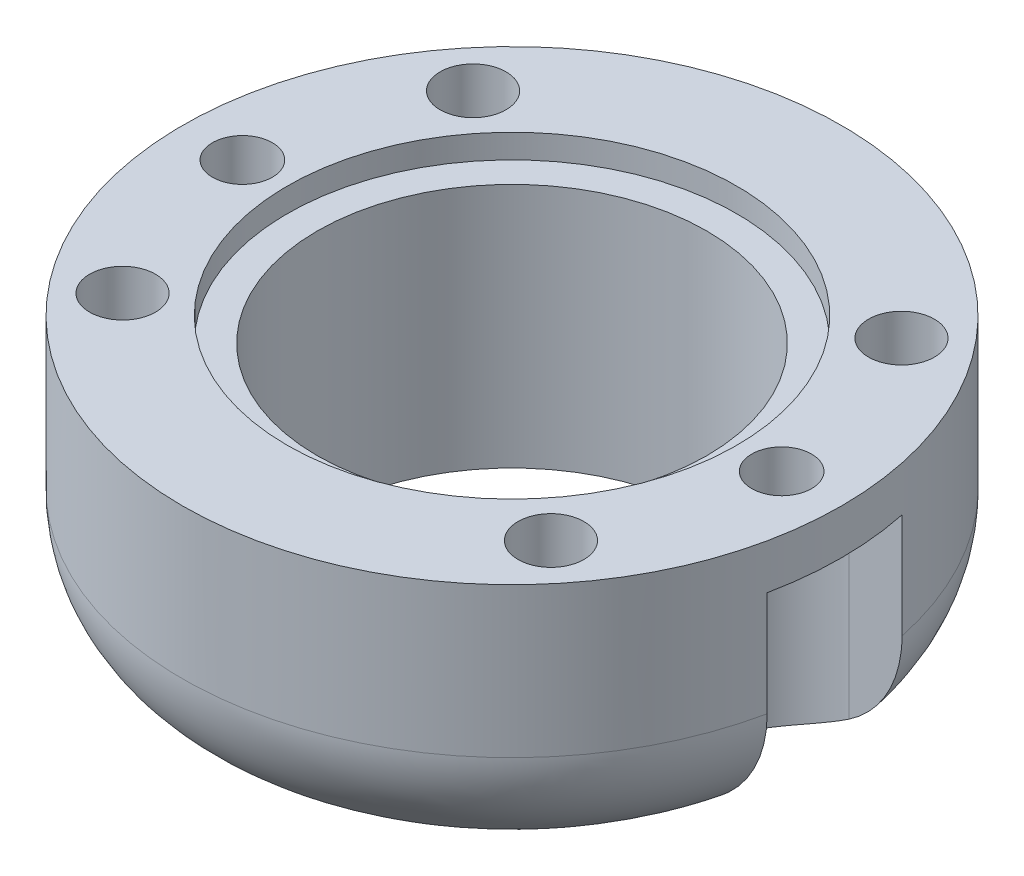
from build123d import *

# Parameters (mm, degrees)
SKETCH1_R           = 6.5
BOSS_EXTRUDE1_DEPTH = 9
SKETCH2_R           = 1.1
CUT_EXTRUDE1_DEPTH  = 3
SKETCH3_R           = 1
CUT_EXTRUDE2_DEPTH  = 20
CUT_EXTRUDE3_DEPTH  = 7.5
SKETCH6_W           = 6.8
SKETCH6_H           = 6.8
CUT_EXTRUDE4_DEPTH  = 5
SKETCH7_W           = 2.4
SKETCH7_H           = 2.4
CUT_EXTRUDE5_DEPTH  = 5
FILLET2_R           = 4
SKETCH8_R           = 1
CUT_EXTRUDE6_DEPTH  = 20
SKETCH9_R           = 7.5
CUT_EXTRUDE7_DEPTH  = 0.8
SKETCH11_W          = 5
SKETCH11_H          = 1
BOSS_EXTRUDE2_DEPTH = 5
SKETCH12_W          = 53.006357488
SKETCH12_H          = 54.029399369
SKETCH12_R          = 11
CUT_EXTRUDE9_DEPTH  = 10
FILLET3_R           = 4


with BuildPart() as part:
    # Sketch1 → Boss-Extrude1 (new body)
    with BuildSketch(Plane(origin=(0, 0, 0), x_dir=(1, 0, 0), z_dir=(0, 1, 0))):
        with BuildLine():
            Line((-11, 0), (-11, 22.01))
            ThreePointArc((-11, 22.01), (-7.781103525, 29.781103525), (-0.01, 33))
            Line((-0.01, 33), (0.01, 33))
            ThreePointArc((0.01, 33), (7.781103525, 29.781103525), (11, 22.01))
            Line((11, 22.01), (11, 0))
            ThreePointArc((11, 0), (0, -11), (-11, 0))
        make_face()
        Circle(SKETCH1_R, mode=Mode.SUBTRACT)
    extrude(amount=BOSS_EXTRUDE1_DEPTH)

    # Sketch2 → Cut-Extrude1 (cut)
    with BuildSketch(Plane(origin=(0, 9, 0), x_dir=(1, 0, 0), z_dir=(0, 1, 0))):
        with Locations((-7.15, 5.85)):
            Circle(SKETCH2_R)
        with Locations((-7.15, -5.85)):
            Circle(SKETCH2_R)
        with Locations((7.15, -5.85)):
            Circle(SKETCH2_R)
        with Locations((7.15, 5.85)):
            Circle(SKETCH2_R)
    extrude(amount=-CUT_EXTRUDE1_DEPTH, mode=Mode.SUBTRACT)

    # Sketch3 → Cut-Extrude2 (cut)
    with BuildSketch(Plane(origin=(0, 9, 0), x_dir=(1, 0, 0), z_dir=(0, 1, 0))):
        with Locations((-9, 0)):
            Circle(SKETCH3_R)
        with Locations((9, 0)):
            Circle(SKETCH3_R)
    extrude(amount=-CUT_EXTRUDE2_DEPTH, mode=Mode.SUBTRACT)

    # Sketch4 → Cut-Extrude3 (cut)
    with BuildSketch(Plane.XZ):
        with BuildLine():
            Line((-9, 2.25), (-10.767427734, 2.25))
            Line((-10.767427734, 2.25), (-12, 0))
            Line((-12, 0), (-11, -2.25))
            Line((-11, -2.25), (-9, -2.25))
            ThreePointArc((-9, -2.25), (-6.75, 0), (-9, 2.25))
        make_face()
        with BuildLine():
            Line((12, 0), (10.767427734, 2.25))
            Line((10.767427734, 2.25), (9, 2.25))
            ThreePointArc((9, 2.25), (6.75, 0), (9, -2.25))
            Line((9, -2.25), (11, -2.25))
            Line((11, -2.25), (12, 0))
        make_face()
    extrude(amount=-CUT_EXTRUDE3_DEPTH, mode=Mode.SUBTRACT)

    # Sketch6 → Cut-Extrude4 (cut)
    with BuildSketch(Plane.XZ):
        with Locations((0, -22.01)):
            Rectangle(SKETCH6_W, SKETCH6_H)
    extrude(amount=-CUT_EXTRUDE4_DEPTH, mode=Mode.SUBTRACT)

    # Sketch7 → Cut-Extrude5 (cut)
    with BuildSketch(Plane.XZ.offset(-5)):
        with Locations((2.2, -19.81)):
            Rectangle(SKETCH7_W, SKETCH7_H)
        with Locations((-2.2, -19.81)):
            Rectangle(SKETCH7_W, SKETCH7_H)
        with Locations((2.2, -24.21)):
            Rectangle(SKETCH7_W, SKETCH7_H)
        with Locations((-2.2, -24.21)):
            Rectangle(SKETCH7_W, SKETCH7_H)
    extrude(amount=-CUT_EXTRUDE5_DEPTH, mode=Mode.SUBTRACT)

    # Fillet2
    fillet2_edges = [part.edges().sort_by_distance(p)[0] for p in [
        (0, 0, 11),
    ]]
    fillet(fillet2_edges, radius=FILLET2_R)

    # Sketch8 → Cut-Extrude6 (cut)
    with BuildSketch(Plane.XZ):
        with Locations((-9, -22.01)):
            Circle(SKETCH8_R)
        with Locations((9, -22.01)):
            Circle(SKETCH8_R)
    extrude(amount=-CUT_EXTRUDE6_DEPTH, mode=Mode.SUBTRACT)

    # Sketch9 → Cut-Extrude7 (cut)
    with BuildSketch(Plane(origin=(0, 9, 0), x_dir=(1, 0, 0), z_dir=(0, 1, 0))):
        Circle(SKETCH9_R)
    extrude(amount=-CUT_EXTRUDE7_DEPTH, mode=Mode.SUBTRACT)

    # Sketch11 → Boss-Extrude2 (add)
    with BuildSketch(Plane.ZY.offset(-3.4)):
        with Locations((-14.185057965, 8.5)):
            Rectangle(SKETCH11_W, SKETCH11_H)
    extrude(amount=BOSS_EXTRUDE2_DEPTH)

    # Sketch12 → Cut-Extrude9 (cut)
    with BuildSketch(Plane.XZ):
        with Locations((2.65351488, -12.086981999)):
            Rectangle(SKETCH12_W, SKETCH12_H)
        Circle(SKETCH12_R, mode=Mode.SUBTRACT)
    extrude(amount=-CUT_EXTRUDE9_DEPTH, mode=Mode.SUBTRACT)

    # Fillet3
    fillet3_edges = [part.edges().sort_by_distance(p)[0] for p in [
        (0, 0, -11),
    ]]
    fillet(fillet3_edges, radius=FILLET3_R)


solid = part.part
